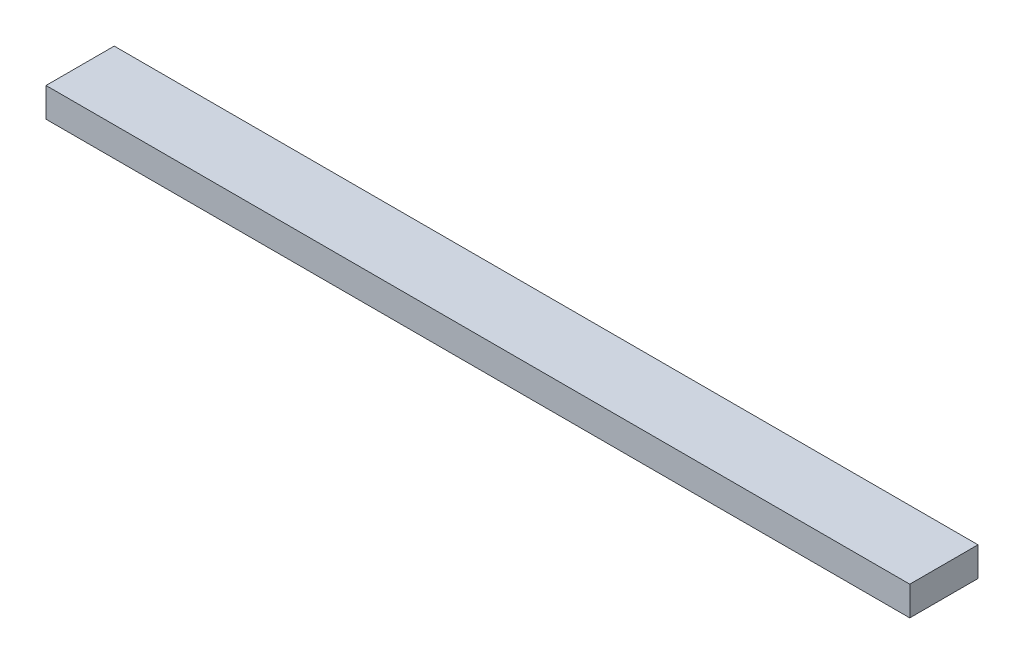
from build123d import *

# Parameters (mm, degrees)
SKETCH1_W           = 1125.5502
SKETCH1_H           = 88.9
BOSS_EXTRUDE1_DEPTH = 38.1


with BuildPart() as part:
    # Sketch1 → Boss-Extrude1 (new body)
    with BuildSketch(Plane(origin=(0, 0, 0), x_dir=(1, 0, 0), z_dir=(0, 1, 0))):
        with Locations((562.7751, 44.45)):
            Rectangle(SKETCH1_W, SKETCH1_H)
    extrude(amount=BOSS_EXTRUDE1_DEPTH)


solid = part.part
